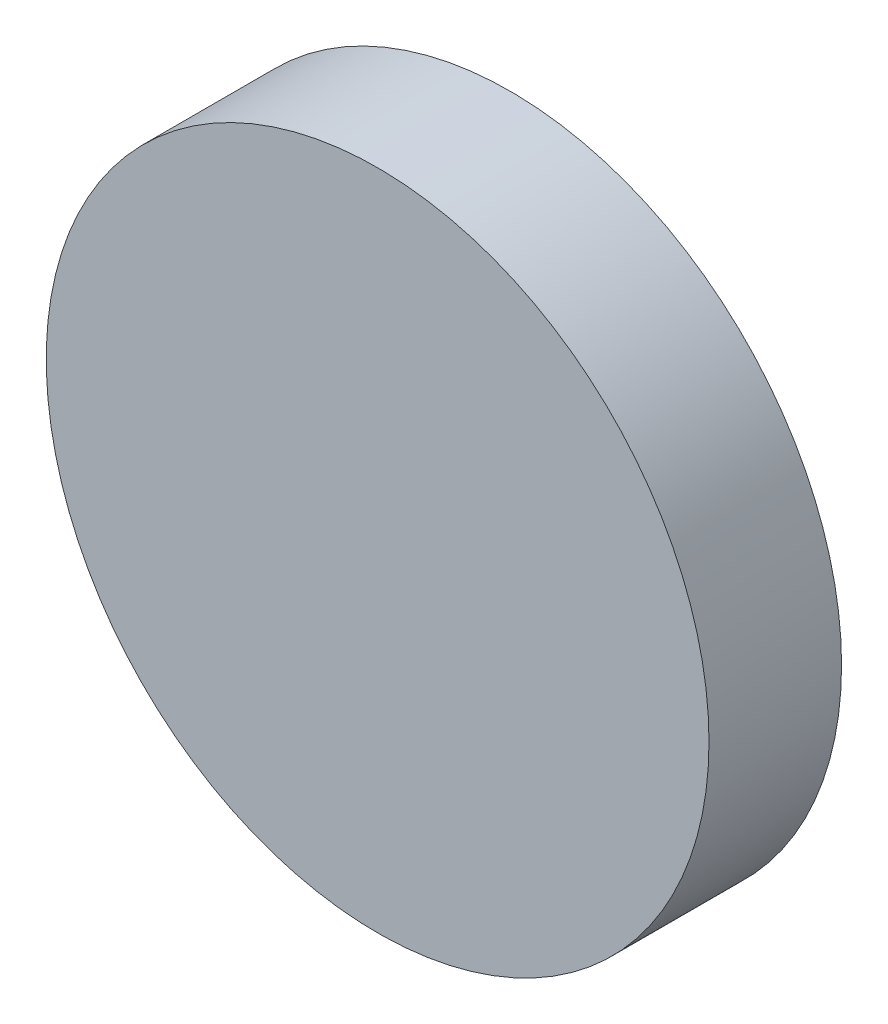
from build123d import *

# Parameters (mm, degrees)
SKETCH_1_R      = 25
EXTRUDE_1_DEPTH = 10


with BuildPart() as part:
    # 草图1 → 凸台-拉伸1 (new body)
    with BuildSketch(Plane.XY):
        Circle(SKETCH_1_R)
    extrude(amount=EXTRUDE_1_DEPTH)


solid = part.part
